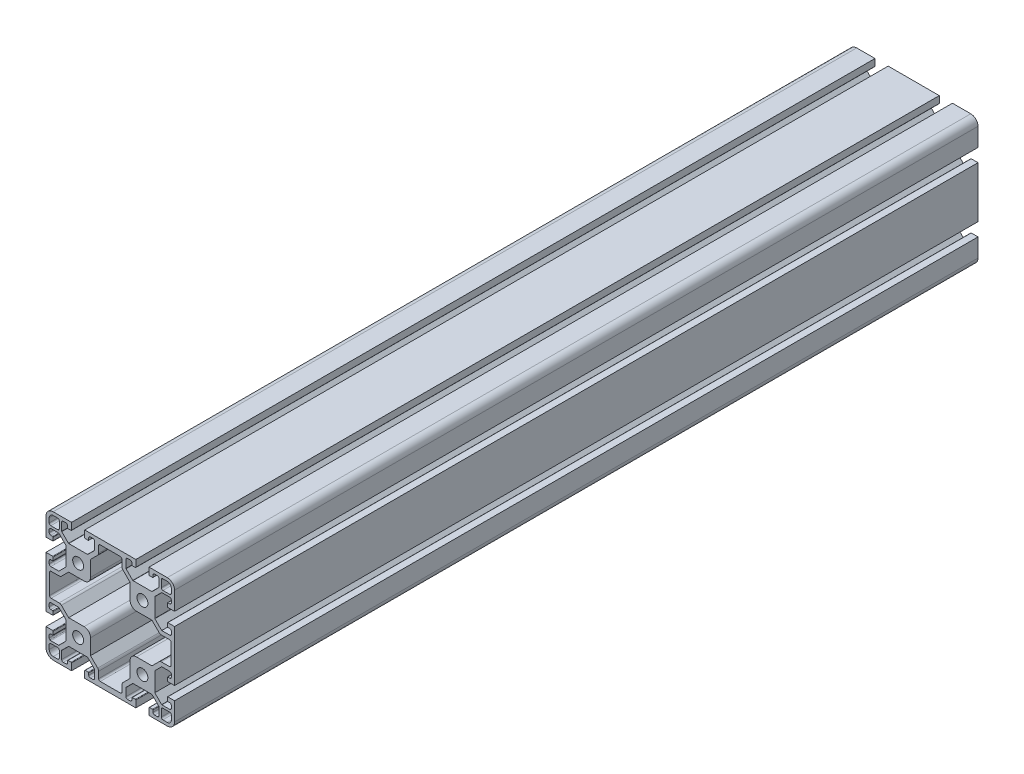
from build123d import *

# Parameters (mm, degrees)
SKETCH1_R           = 3.4
BOSS_EXTRUDE1_DEPTH = 500


with BuildPart() as part:
    # Sketch1 → Boss-Extrude1 (new body)
    with BuildSketch(Plane.XY):
        with BuildLine():
            Line((-15.9, -35.8), (-15.9, -40))
            Line((-15.9, -40), (15.9, -40))
            Line((15.9, -40), (15.9, -35.8))
            ThreePointArc((15.9, -35.8), (15.812132034, -35.587867966), (15.6, -35.5))
            Line((15.6, -35.5), (13.7, -35.5))
            ThreePointArc((13.7, -35.5), (13.487867966, -35.587867966), (13.4, -35.8))
            Line((13.4, -35.8), (13.4, -37))
            ThreePointArc((13.4, -37), (13.107106781, -37.707106781), (12.4, -38))
            Line((12.4, -38), (10.75, -38))
            ThreePointArc((10.75, -38), (10.042893219, -37.707106781), (9.75, -37))
            Line((9.75, -37), (9.75, -32.142031022))
            ThreePointArc((9.75, -32.142031022), (9.77283614, -32.027225992), (9.837867966, -31.929898987))
            Line((9.837867966, -31.929898987), (13.979898987, -27.787867966))
            ThreePointArc((13.979898987, -27.787867966), (14.077225992, -27.72283614), (14.192031022, -27.7))
            Line((14.192031022, -27.7), (25.807968978, -27.7))
            ThreePointArc((25.807968978, -27.7), (25.922774008, -27.72283614), (26.020101013, -27.787867966))
            Line((26.020101013, -27.787867966), (30.162132034, -31.929898987))
            ThreePointArc((30.162132034, -31.929898987), (30.22716386, -32.027225992), (30.25, -32.142031022))
            Line((30.25, -32.142031022), (30.25, -37))
            ThreePointArc((30.25, -37), (29.957106781, -37.707106781), (29.25, -38))
            Line((29.25, -38), (27.6, -38))
            ThreePointArc((27.6, -38), (26.892893219, -37.707106781), (26.6, -37))
            Line((26.6, -37), (26.6, -35.8))
            ThreePointArc((26.6, -35.8), (26.512132034, -35.587867966), (26.3, -35.5))
            Line((26.3, -35.5), (24.4, -35.5))
            ThreePointArc((24.4, -35.5), (24.187867966, -35.587867966), (24.1, -35.8))
            Line((24.1, -35.8), (24.1, -40))
            Line((24.1, -40), (35.5, -40))
            ThreePointArc((35.5, -40), (38.681980515, -38.681980515), (40, -35.5))
            Line((40, -35.5), (40, -24.1))
            Line((40, -24.1), (35.8, -24.1))
            ThreePointArc((35.8, -24.1), (35.587867966, -24.187867966), (35.5, -24.4))
            Line((35.5, -24.4), (35.5, -26.3))
            ThreePointArc((35.5, -26.3), (35.587867966, -26.512132034), (35.8, -26.6))
            Line((35.8, -26.6), (37, -26.6))
            ThreePointArc((37, -26.6), (37.707106781, -26.892893219), (38, -27.6))
            Line((38, -27.6), (38, -29.25))
            ThreePointArc((38, -29.25), (37.707106781, -29.957106781), (37, -30.25))
            Line((37, -30.25), (32.142031022, -30.25))
            ThreePointArc((32.142031022, -30.25), (32.027225992, -30.22716386), (31.929898987, -30.162132034))
            Line((31.929898987, -30.162132034), (27.7, -25.932233047))
            Line((27.7, -25.932233047), (27.7, -14.067766953))
            Line((27.7, -14.067766953), (32.017766953, -9.75))
            Line((32.017766953, -9.75), (37, -9.75))
            ThreePointArc((37, -9.75), (37.707106781, -10.042893219), (38, -10.75))
            Line((38, -10.75), (38, -12.4))
            ThreePointArc((38, -12.4), (37.707106781, -13.107106781), (37, -13.4))
            Line((37, -13.4), (35.8, -13.4))
            ThreePointArc((35.8, -13.4), (35.587867966, -13.487867966), (35.5, -13.7))
            Line((35.5, -13.7), (35.5, -15.6))
            ThreePointArc((35.5, -15.6), (35.587867966, -15.812132034), (35.8, -15.9))
            Line((35.8, -15.9), (40, -15.9))
            Line((40, -15.9), (40, 15.9))
            Line((40, 15.9), (35.8, 15.9))
            ThreePointArc((35.8, 15.9), (35.587867966, 15.812132034), (35.5, 15.6))
            Line((35.5, 15.6), (35.5, 13.7))
            ThreePointArc((35.5, 13.7), (35.587867966, 13.487867966), (35.8, 13.4))
            Line((35.8, 13.4), (37, 13.4))
            ThreePointArc((37, 13.4), (37.707106781, 13.107106781), (38, 12.4))
            Line((38, 12.4), (38, 10.75))
            ThreePointArc((38, 10.75), (37.707106781, 10.042893219), (37, 9.75))
            Line((37, 9.75), (32.017766953, 9.75))
            Line((32.017766953, 9.75), (27.787867966, 13.979898987))
            ThreePointArc((27.787867966, 13.979898987), (27.72283614, 14.077225992), (27.7, 14.192031022))
            Line((27.7, 14.192031022), (27.7, 25.807968978))
            ThreePointArc((27.7, 25.807968978), (27.72283614, 25.922774008), (27.787867966, 26.020101013))
            Line((27.787867966, 26.020101013), (31.929898987, 30.162132034))
            ThreePointArc((31.929898987, 30.162132034), (32.027225992, 30.22716386), (32.142031022, 30.25))
            Line((32.142031022, 30.25), (37, 30.25))
            ThreePointArc((37, 30.25), (37.707106781, 29.957106781), (38, 29.25))
            Line((38, 29.25), (38, 27.6))
            ThreePointArc((38, 27.6), (37.707106781, 26.892893219), (37, 26.6))
            Line((37, 26.6), (35.8, 26.6))
            ThreePointArc((35.8, 26.6), (35.587867966, 26.512132034), (35.5, 26.3))
            Line((35.5, 26.3), (35.5, 24.4))
            ThreePointArc((35.5, 24.4), (35.587867966, 24.187867966), (35.8, 24.1))
            Line((35.8, 24.1), (40, 24.1))
            Line((40, 24.1), (40, 35.5))
            ThreePointArc((40, 35.5), (38.681980515, 38.681980515), (35.5, 40))
            Line((35.5, 40), (24.1, 40))
            Line((24.1, 40), (24.1, 35.8))
            ThreePointArc((24.1, 35.8), (24.187867966, 35.587867966), (24.4, 35.5))
            Line((24.4, 35.5), (26.3, 35.5))
            ThreePointArc((26.3, 35.5), (26.512132034, 35.587867966), (26.6, 35.8))
            Line((26.6, 35.8), (26.6, 37))
            ThreePointArc((26.6, 37), (26.892893219, 37.707106781), (27.6, 38))
            Line((27.6, 38), (29.25, 38))
            ThreePointArc((29.25, 38), (29.957106781, 37.707106781), (30.25, 37))
            Line((30.25, 37), (30.25, 32.142031022))
            ThreePointArc((30.25, 32.142031022), (30.22716386, 32.027225992), (30.162132034, 31.929898987))
            Line((30.162132034, 31.929898987), (26.020101013, 27.787867966))
            ThreePointArc((26.020101013, 27.787867966), (25.922774008, 27.72283614), (25.807968978, 27.7))
            Line((25.807968978, 27.7), (14.192031022, 27.7))
            ThreePointArc((14.192031022, 27.7), (14.077225992, 27.72283614), (13.979898987, 27.787867966))
            Line((13.979898987, 27.787867966), (9.837867966, 31.929898987))
            ThreePointArc((9.837867966, 31.929898987), (9.77283614, 32.027225992), (9.75, 32.142031022))
            Line((9.75, 32.142031022), (9.75, 37))
            ThreePointArc((9.75, 37), (10.042893219, 37.707106781), (10.75, 38))
            Line((10.75, 38), (12.4, 38))
            ThreePointArc((12.4, 38), (13.107106781, 37.707106781), (13.4, 37))
            Line((13.4, 37), (13.4, 35.8))
            ThreePointArc((13.4, 35.8), (13.487867966, 35.587867966), (13.7, 35.5))
            Line((13.7, 35.5), (15.6, 35.5))
            ThreePointArc((15.6, 35.5), (15.812132034, 35.587867966), (15.9, 35.8))
            Line((15.9, 35.8), (15.9, 40))
            Line((15.9, 40), (-15.9, 40))
            Line((-15.9, 40), (-15.9, 35.8))
            ThreePointArc((-15.9, 35.8), (-15.812132034, 35.587867966), (-15.6, 35.5))
            Line((-15.6, 35.5), (-13.7, 35.5))
            ThreePointArc((-13.7, 35.5), (-13.487867966, 35.587867966), (-13.4, 35.8))
            Line((-13.4, 35.8), (-13.4, 37))
            ThreePointArc((-13.4, 37), (-13.107106781, 37.707106781), (-12.4, 38))
            Line((-12.4, 38), (-10.75, 38))
            ThreePointArc((-10.75, 38), (-10.042893219, 37.707106781), (-9.75, 37))
            Line((-9.75, 37), (-9.75, 32.142031022))
            ThreePointArc((-9.75, 32.142031022), (-9.77283614, 32.027225992), (-9.837867966, 31.929898987))
            Line((-9.837867966, 31.929898987), (-13.979898987, 27.787867966))
            ThreePointArc((-13.979898987, 27.787867966), (-14.077225992, 27.72283614), (-14.192031022, 27.7))
            Line((-14.192031022, 27.7), (-25.807968978, 27.7))
            ThreePointArc((-25.807968978, 27.7), (-25.922774008, 27.72283614), (-26.020101013, 27.787867966))
            Line((-26.020101013, 27.787867966), (-30.162132034, 31.929898987))
            ThreePointArc((-30.162132034, 31.929898987), (-30.22716386, 32.027225992), (-30.25, 32.142031022))
            Line((-30.25, 32.142031022), (-30.25, 37))
            ThreePointArc((-30.25, 37), (-29.957106781, 37.707106781), (-29.25, 38))
            Line((-29.25, 38), (-27.6, 38))
            ThreePointArc((-27.6, 38), (-26.892893219, 37.707106781), (-26.6, 37))
            Line((-26.6, 37), (-26.6, 35.8))
            ThreePointArc((-26.6, 35.8), (-26.512132034, 35.587867966), (-26.3, 35.5))
            Line((-26.3, 35.5), (-24.4, 35.5))
            ThreePointArc((-24.4, 35.5), (-24.187867966, 35.587867966), (-24.1, 35.8))
            Line((-24.1, 35.8), (-24.1, 40))
            Line((-24.1, 40), (-35.5, 40))
            ThreePointArc((-35.5, 40), (-38.681980515, 38.681980515), (-40, 35.5))
            Line((-40, 35.5), (-40, 24.1))
            Line((-40, 24.1), (-35.8, 24.1))
            ThreePointArc((-35.8, 24.1), (-35.587867966, 24.187867966), (-35.5, 24.4))
            Line((-35.5, 24.4), (-35.5, 26.3))
            ThreePointArc((-35.5, 26.3), (-35.587867966, 26.512132034), (-35.8, 26.6))
            Line((-35.8, 26.6), (-37, 26.6))
            ThreePointArc((-37, 26.6), (-37.707106781, 26.892893219), (-38, 27.6))
            Line((-38, 27.6), (-38, 29.25))
            ThreePointArc((-38, 29.25), (-37.707106781, 29.957106781), (-37, 30.25))
            Line((-37, 30.25), (-32.142031022, 30.25))
            ThreePointArc((-32.142031022, 30.25), (-32.027225992, 30.22716386), (-31.929898987, 30.162132034))
            Line((-31.929898987, 30.162132034), (-27.787867966, 26.020101013))
            ThreePointArc((-27.787867966, 26.020101013), (-27.72283614, 25.922774008), (-27.7, 25.807968978))
            Line((-27.7, 25.807968978), (-27.7, 14.192031022))
            ThreePointArc((-27.7, 14.192031022), (-27.72283614, 14.077225992), (-27.787867966, 13.979898987))
            Line((-27.787867966, 13.979898987), (-32.017766953, 9.75))
            Line((-32.017766953, 9.75), (-37, 9.75))
            ThreePointArc((-37, 9.75), (-37.707106781, 10.042893219), (-38, 10.75))
            Line((-38, 10.75), (-38, 12.4))
            ThreePointArc((-38, 12.4), (-37.707106781, 13.107106781), (-37, 13.4))
            Line((-37, 13.4), (-35.8, 13.4))
            ThreePointArc((-35.8, 13.4), (-35.587867966, 13.487867966), (-35.5, 13.7))
            Line((-35.5, 13.7), (-35.5, 15.6))
            ThreePointArc((-35.5, 15.6), (-35.587867966, 15.812132034), (-35.8, 15.9))
            Line((-35.8, 15.9), (-40, 15.9))
            Line((-40, 15.9), (-40, -15.9))
            Line((-40, -15.9), (-35.8, -15.9))
            ThreePointArc((-35.8, -15.9), (-35.587867966, -15.812132034), (-35.5, -15.6))
            Line((-35.5, -15.6), (-35.5, -13.7))
            ThreePointArc((-35.5, -13.7), (-35.587867966, -13.487867966), (-35.8, -13.4))
            Line((-35.8, -13.4), (-37, -13.4))
            ThreePointArc((-37, -13.4), (-37.707106781, -13.107106781), (-38, -12.4))
            Line((-38, -12.4), (-38, -10.75))
            ThreePointArc((-38, -10.75), (-37.707106781, -10.042893219), (-37, -9.75))
            Line((-37, -9.75), (-32.017766953, -9.75))
            Line((-32.017766953, -9.75), (-27.787867966, -13.979898987))
            ThreePointArc((-27.787867966, -13.979898987), (-27.72283614, -14.077225992), (-27.7, -14.192031022))
            Line((-27.7, -14.192031022), (-27.7, -25.807968978))
            ThreePointArc((-27.7, -25.807968978), (-27.72283614, -25.922774008), (-27.787867966, -26.020101013))
            Line((-27.787867966, -26.020101013), (-31.929898987, -30.162132034))
            ThreePointArc((-31.929898987, -30.162132034), (-32.027225992, -30.22716386), (-32.142031022, -30.25))
            Line((-32.142031022, -30.25), (-37, -30.25))
            ThreePointArc((-37, -30.25), (-37.305622961, -30.202152617), (-37.581999403, -30.063189212))
            add(Edge.make_bspline(
                [(-37.581999403, -30.063189212), (-37.589191393, -30.058041906), (-37.596313212, -30.052800564), (-37.603364896, -30.047465236)],
                knots=[0, 0, 0, 0, 1, 1, 1, 1], degree=3))
            ThreePointArc((-37.603364896, -30.047465236), (-37.895367214, -29.695328589), (-38, -29.25))
            Line((-38, -29.25), (-38, -27.6))
            ThreePointArc((-38, -27.6), (-37.707106781, -26.892893219), (-37, -26.6))
            Line((-37, -26.6), (-35.8, -26.6))
            ThreePointArc((-35.8, -26.6), (-35.587867966, -26.512132034), (-35.5, -26.3))
            Line((-35.5, -26.3), (-35.5, -24.4))
            ThreePointArc((-35.5, -24.4), (-35.587867966, -24.187867966), (-35.8, -24.1))
            Line((-35.8, -24.1), (-40, -24.1))
            Line((-40, -24.1), (-40, -35.5))
            ThreePointArc((-40, -35.5), (-38.681980515, -38.681980515), (-35.5, -40))
            Line((-35.5, -40), (-24.1, -40))
            Line((-24.1, -40), (-24.1, -35.8))
            ThreePointArc((-24.1, -35.8), (-24.187867966, -35.587867966), (-24.4, -35.5))
            Line((-24.4, -35.5), (-26.3, -35.5))
            ThreePointArc((-26.3, -35.5), (-26.512132034, -35.587867966), (-26.6, -35.8))
            Line((-26.6, -35.8), (-26.6, -37))
            ThreePointArc((-26.6, -37), (-26.892893219, -37.707106781), (-27.6, -38))
            Line((-27.6, -38), (-29.25, -38))
            ThreePointArc((-29.25, -38), (-29.957106781, -37.707106781), (-30.25, -37))
            Line((-30.25, -37), (-30.25, -32.142031022))
            ThreePointArc((-30.25, -32.142031022), (-30.22716386, -32.027225992), (-30.162132034, -31.929898987))
            Line((-30.162132034, -31.929898987), (-26.020101013, -27.787867966))
            ThreePointArc((-26.020101013, -27.787867966), (-25.922774008, -27.72283614), (-25.807968978, -27.7))
            Line((-25.807968978, -27.7), (-14.192031022, -27.7))
            ThreePointArc((-14.192031022, -27.7), (-14.077225992, -27.72283614), (-13.979898987, -27.787867966))
            Line((-13.979898987, -27.787867966), (-9.837867966, -31.929898987))
            ThreePointArc((-9.837867966, -31.929898987), (-9.77283614, -32.027225992), (-9.75, -32.142031022))
            Line((-9.75, -32.142031022), (-9.75, -37))
            ThreePointArc((-9.75, -37), (-10.042893219, -37.707106781), (-10.75, -38))
            Line((-10.75, -38), (-12.4, -38))
            ThreePointArc((-12.4, -38), (-13.107106781, -37.707106781), (-13.4, -37))
            Line((-13.4, -37), (-13.4, -35.8))
            ThreePointArc((-13.4, -35.8), (-13.487867966, -35.587867966), (-13.7, -35.5))
            Line((-13.7, -35.5), (-15.6, -35.5))
            ThreePointArc((-15.6, -35.5), (-15.812132034, -35.587867966), (-15.9, -35.8))
        make_face()
        with Locations((-20, -20)):
            Circle(SKETCH1_R, mode=Mode.SUBTRACT)
        with Locations((20, 20)):
            Circle(SKETCH1_R, mode=Mode.SUBTRACT)
        with Locations((-20, 20)):
            Circle(SKETCH1_R, mode=Mode.SUBTRACT)
        with Locations((20, -20)):
            Circle(SKETCH1_R, mode=Mode.SUBTRACT)
        with BuildLine():
            Line((-7.835786438, 30.396446609), (-12.3, 25.932233047))
            Line((-12.3, 25.932233047), (-12.3, 16.3))
            ThreePointArc((-12.3, 16.3), (-13.471572875, 13.471572875), (-16.3, 12.3))
            Line((-16.3, 12.3), (-25.932233047, 12.3))
            Line((-25.932233047, 12.3), (-30.396446609, 7.835786438))
            ThreePointArc((-30.396446609, 7.835786438), (-31.045293307, 7.402240935), (-31.810660172, 7.25))
            Line((-31.810660172, 7.25), (-36.8, 7.25))
            ThreePointArc((-36.8, 7.25), (-37.507106781, 6.957106781), (-37.8, 6.25))
            Line((-37.8, 6.25), (-37.8, -6.25))
            ThreePointArc((-37.8, -6.25), (-37.507106781, -6.957106781), (-36.8, -7.25))
            Line((-36.8, -7.25), (-31.810660172, -7.25))
            ThreePointArc((-31.810660172, -7.25), (-31.045293307, -7.402240935), (-30.396446609, -7.835786438))
            Line((-30.396446609, -7.835786438), (-25.932233047, -12.3))
            Line((-25.932233047, -12.3), (-16.3, -12.3))
            ThreePointArc((-16.3, -12.3), (-13.471572875, -13.471572875), (-12.3, -16.3))
            Line((-12.3, -16.3), (-12.3, -25.932233047))
            Line((-12.3, -25.932233047), (-7.835786438, -30.396446609))
            ThreePointArc((-7.835786438, -30.396446609), (-7.402240935, -31.045293307), (-7.25, -31.810660172))
            Line((-7.25, -31.810660172), (-7.25, -35.8))
            ThreePointArc((-7.25, -35.8), (-6.957106781, -36.507106781), (-6.25, -36.8))
            Line((-6.25, -36.8), (6.25, -36.8))
            ThreePointArc((6.25, -36.8), (6.957106781, -36.507106781), (7.25, -35.8))
            Line((7.25, -35.8), (7.25, -31.810660172))
            ThreePointArc((7.25, -31.810660172), (7.402240935, -31.045293307), (7.835786438, -30.396446609))
            Line((7.835786438, -30.396446609), (12.3, -25.932233047))
            Line((12.3, -25.932233047), (12.3, -16.3))
            ThreePointArc((12.3, -16.3), (13.471572875, -13.471572875), (16.3, -12.3))
            Line((16.3, -12.3), (25.932233047, -12.3))
            Line((25.932233047, -12.3), (30.396446609, -7.835786438))
            ThreePointArc((30.396446609, -7.835786438), (31.045293307, -7.402240935), (31.810660172, -7.25))
            Line((31.810660172, -7.25), (36.8, -7.25))
            ThreePointArc((36.8, -7.25), (37.507106781, -6.957106781), (37.8, -6.25))
            Line((37.8, -6.25), (37.8, 6.25))
            ThreePointArc((37.8, 6.25), (37.507106781, 6.957106781), (36.8, 7.25))
            Line((36.8, 7.25), (31.810660172, 7.25))
            ThreePointArc((31.810660172, 7.25), (31.045293307, 7.402240935), (30.396446609, 7.835786438))
            Line((30.396446609, 7.835786438), (25.932233047, 12.3))
            Line((25.932233047, 12.3), (16.3, 12.3))
            ThreePointArc((16.3, 12.3), (13.471572875, 13.471572875), (12.3, 16.3))
            Line((12.3, 16.3), (12.3, 25.932233047))
            Line((12.3, 25.932233047), (7.835786438, 30.396446609))
            ThreePointArc((7.835786438, 30.396446609), (7.402240935, 31.045293307), (7.25, 31.810660172))
            Line((7.25, 31.810660172), (7.25, 35.8))
            ThreePointArc((7.25, 35.8), (6.957106781, 36.507106781), (6.25, 36.8))
            Line((6.25, 36.8), (-6.25, 36.8))
            ThreePointArc((-6.25, 36.8), (-6.957106781, 36.507106781), (-7.25, 35.8))
            Line((-7.25, 35.8), (-7.25, 31.810660172))
            ThreePointArc((-7.25, 31.810660172), (-7.402240935, 31.045293307), (-7.835786438, 30.396446609))
        make_face(mode=Mode.SUBTRACT)
        with BuildLine():
            Line((-32.75, -31.75), (-37, -31.75))
            ThreePointArc((-37, -31.75), (-37.707106781, -32.042893219), (-38, -32.75))
            Line((-38, -32.75), (-38, -35.5))
            ThreePointArc((-38, -35.5), (-37.267766953, -37.267766953), (-35.5, -38))
            Line((-35.5, -38), (-32.75, -38))
            ThreePointArc((-32.75, -38), (-32.042893219, -37.707106781), (-31.75, -37))
            Line((-31.75, -37), (-31.75, -32.75))
            ThreePointArc((-31.75, -32.75), (-32.042893219, -32.042893219), (-32.75, -31.75))
        make_face(mode=Mode.SUBTRACT)
        with BuildLine():
            Line((-31.75, 32.75), (-31.75, 37))
            ThreePointArc((-31.75, 37), (-32.042893219, 37.707106781), (-32.75, 38))
            Line((-32.75, 38), (-35.5, 38))
            ThreePointArc((-35.5, 38), (-37.267766953, 37.267766953), (-38, 35.5))
            Line((-38, 35.5), (-38, 32.75))
            ThreePointArc((-38, 32.75), (-37.707106781, 32.042893219), (-37, 31.75))
            Line((-37, 31.75), (-32.75, 31.75))
            ThreePointArc((-32.75, 31.75), (-32.042893219, 32.042893219), (-31.75, 32.75))
        make_face(mode=Mode.SUBTRACT)
        with BuildLine():
            Line((31.75, -32.75), (31.75, -37))
            ThreePointArc((31.75, -37), (32.042893219, -37.707106781), (32.75, -38))
            Line((32.75, -38), (35.5, -38))
            ThreePointArc((35.5, -38), (37.267766953, -37.267766953), (38, -35.5))
            Line((38, -35.5), (38, -32.75))
            ThreePointArc((38, -32.75), (37.707106781, -32.042893219), (37, -31.75))
            Line((37, -31.75), (32.75, -31.75))
            ThreePointArc((32.75, -31.75), (32.042893219, -32.042893219), (31.75, -32.75))
        make_face(mode=Mode.SUBTRACT)
        with BuildLine():
            Line((32.75, 31.75), (37, 31.75))
            ThreePointArc((37, 31.75), (37.707106781, 32.042893219), (38, 32.75))
            Line((38, 32.75), (38, 35.5))
            ThreePointArc((38, 35.5), (37.267766953, 37.267766953), (35.5, 38))
            Line((35.5, 38), (32.75, 38))
            ThreePointArc((32.75, 38), (32.042893219, 37.707106781), (31.75, 37))
            Line((31.75, 37), (31.75, 32.75))
            ThreePointArc((31.75, 32.75), (32.042893219, 32.042893219), (32.75, 31.75))
        make_face(mode=Mode.SUBTRACT)
    extrude(amount=BOSS_EXTRUDE1_DEPTH)


solid = part.part
